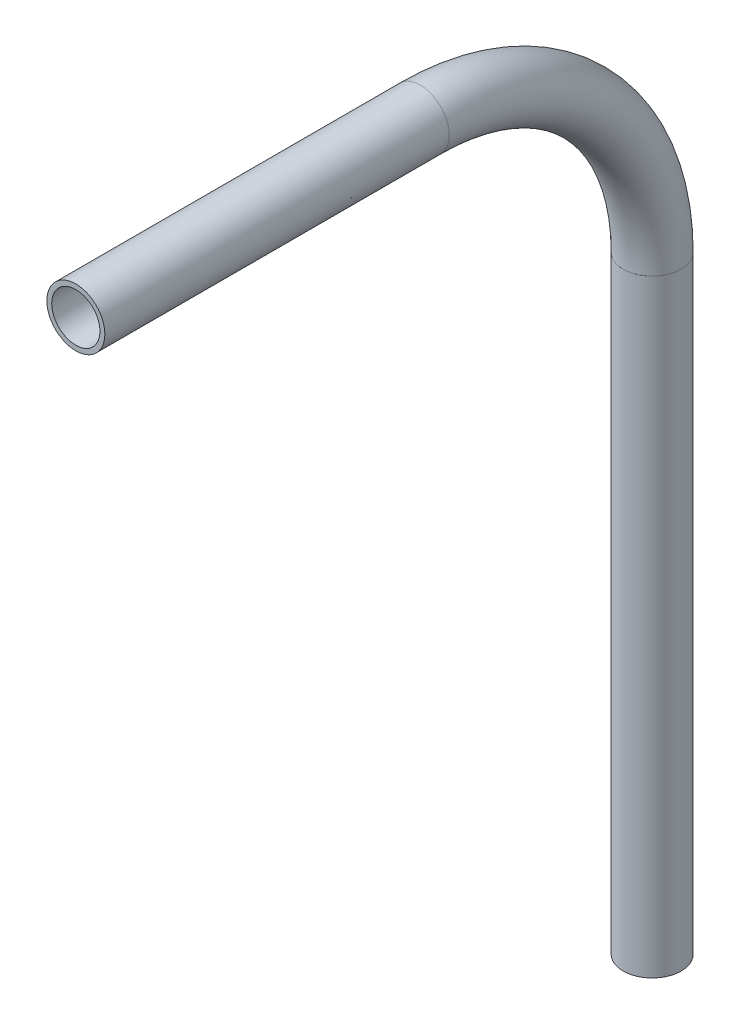
from build123d import *

# Parameters (mm, degrees)
SKETCH11_R                = 6.35
SKETCH11_R_2              = 5.2832
PIPE_0_5_SCH_40_1_DEPTH   = 133.132879549
SKETCH11_ON_SEGMENT_2_R   = 6.35
SKETCH11_ON_SEGMENT_2_R_2 = 5.2832
PIPE_0_5_SCH_40_1_2_ANGLE = 90
SKETCH11_ON_SEGMENT_3_R   = 6.35
SKETCH11_ON_SEGMENT_3_R_2 = 5.2832
PIPE_0_5_SCH_40_1_3_DEPTH = 75.434862272


with BuildPart() as part:
    # Sketch11 → Pipe 0.5 SCH 40(1) (new body)
    with BuildSketch(Plane(origin=(0, 1009.74779895, 310.130117333), x_dir=(0, 0, 1), z_dir=(0, 1, 0))):
        Circle(SKETCH11_R)
        Circle(SKETCH11_R_2, mode=Mode.SUBTRACT)
    extrude(amount=PIPE_0_5_SCH_40_1_DEPTH)


with BuildPart() as body_2:
    # Sketch11 on segment 2 (carried to the start of arc 2) → Pipe 0.5 SCH 40_1 2 (revolve)
    with BuildSketch(Plane(origin=(0, 1142.880678498, 310.130117333), x_dir=(0, 0, 1), z_dir=(0, 1, 0))):
        Circle(SKETCH11_ON_SEGMENT_2_R)
        Circle(SKETCH11_ON_SEGMENT_2_R_2, mode=Mode.SUBTRACT)
    revolve(axis=Axis((0, 1142.880678498, 360.930117333), (1, 0, 0)), revolution_arc=PIPE_0_5_SCH_40_1_2_ANGLE)


with BuildPart() as body_3:
    # Sketch11 on segment 3 (carried to segment 3) → Pipe 0.5 SCH 40_1 3 (new body)
    with BuildSketch(Plane(origin=(0, 1193.680678498, 436.364979606), x_dir=(0, 1, 0), z_dir=(0, 0, -1))):
        Circle(SKETCH11_ON_SEGMENT_3_R)
        Circle(SKETCH11_ON_SEGMENT_3_R_2, mode=Mode.SUBTRACT)
    extrude(amount=PIPE_0_5_SCH_40_1_3_DEPTH)


solid = Compound([part.part, body_2.part, body_3.part])
